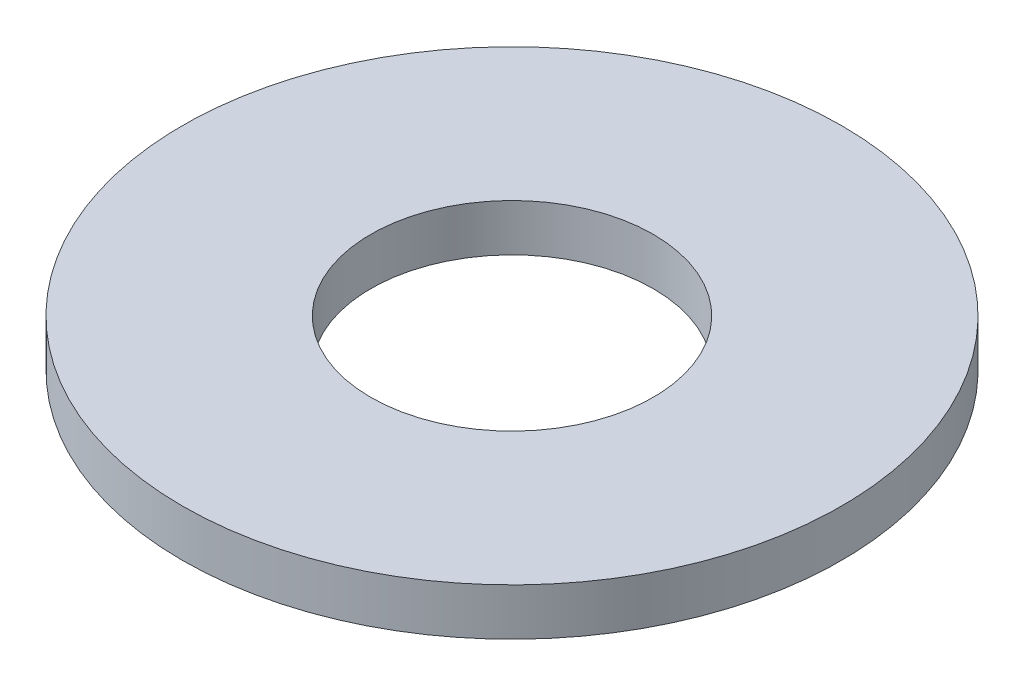
from build123d import *

# Parameters (mm, degrees)
SKETCH_1_R      = 3.5
SKETCH_1_R_2    = 1.5
EXTRUDE_1_DEPTH = 0.5


with BuildPart() as part:
    # 草图1 → 凸台-拉伸1 (new body)
    with BuildSketch(Plane(origin=(0, 0, 0), x_dir=(1, 0, 0), z_dir=(0, 1, 0))):
        Circle(SKETCH_1_R)
        Circle(SKETCH_1_R_2, mode=Mode.SUBTRACT)
    extrude(amount=EXTRUDE_1_DEPTH)


solid = part.part
